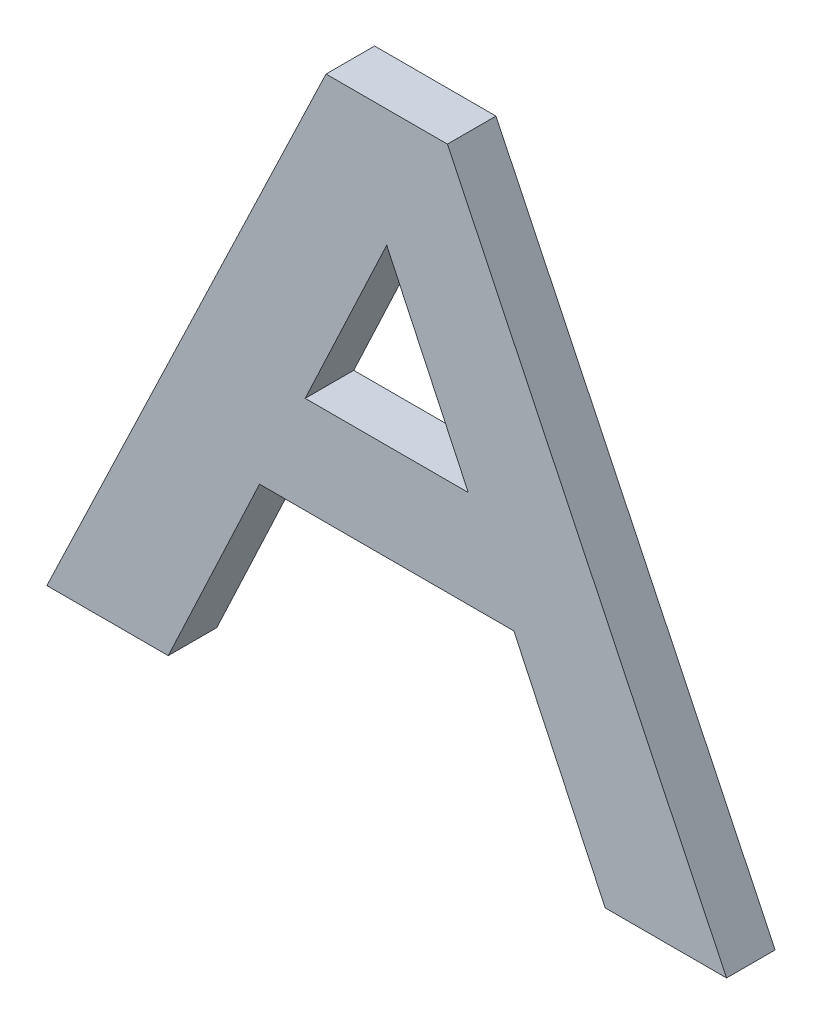
from build123d import *

# Parameters (mm, degrees)
BOSS_EXTRUDE3_DEPTH = 6.35


with BuildPart() as part:
    # Sketch1 → Boss-Extrude3 (new body)
    with BuildSketch(Plane.XY):
        Polygon((0, 60.785489465), (0, 76.2), (-7.9375, 76.2), (-44.45, 0), (-28.575, 0), (-16.634568058, 25.4), (0, 25.4), (0, 38.1), (-10.664352087, 38.1), align=None)
        Polygon((7.9375, 76.2), (0, 76.2), (0, 60.785489465), (10.664352087, 38.1), (0, 38.1), (0, 25.4), (16.634568058, 25.4), (28.575, 0), (44.45, 0), align=None)
    extrude(amount=BOSS_EXTRUDE3_DEPTH)


solid = part.part
